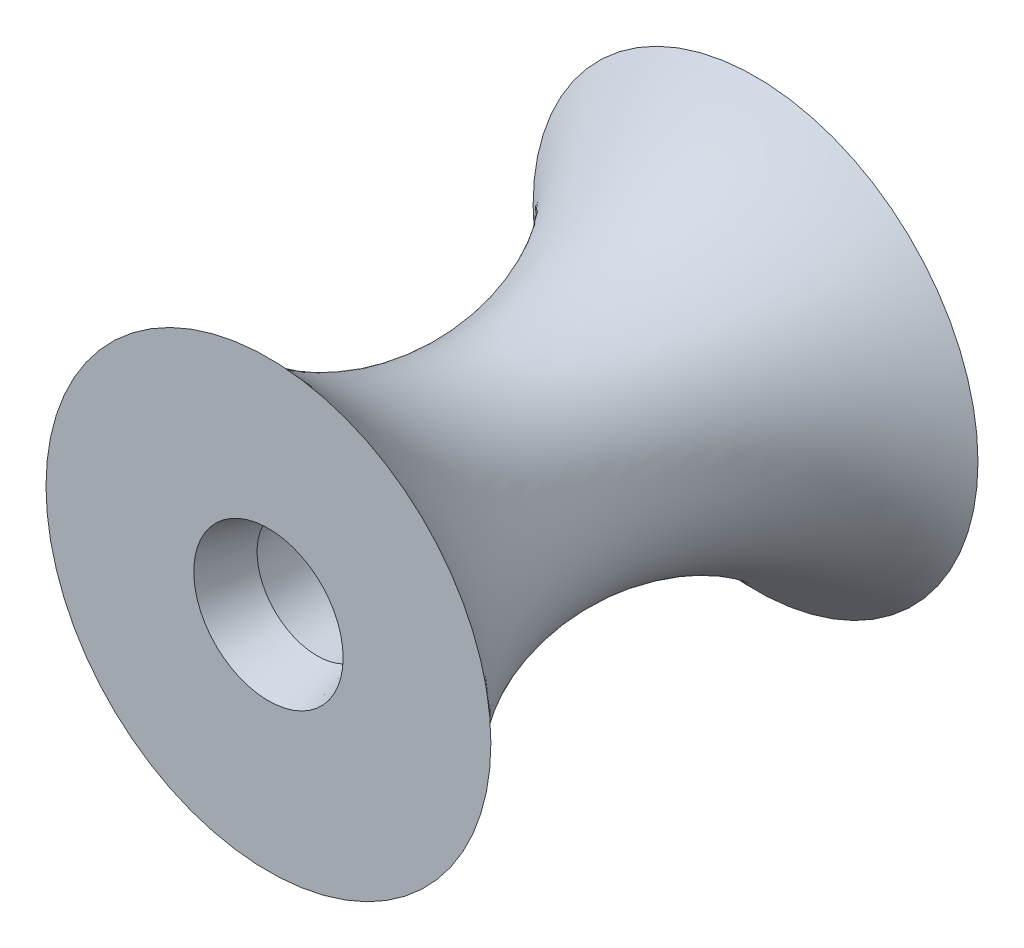
from build123d import *


with BuildPart() as part:
    # Sketch1 → Revolve1 (revolve)
    with BuildSketch(Plane(origin=(0, 0, 0), x_dir=(1, 0, 0), z_dir=(0, 1, 0))):
        with BuildLine():
            Line((-1.85, 13.5), (-1.85, 1.5))
            Line((-1.85, 1.5), (-2.3, 0))
            Line((-2.3, 0), (-6.85, 0))
            ThreePointArc((-6.85, 0), (-3.35, 7.5), (-6.85, 15))
            Line((-6.85, 15), (-2.3, 15))
            Line((-2.3, 15), (-1.85, 13.5))
        make_face()
    revolve(axis=Axis((0, 0, 0), (0, 0, -1)))


solid = part.part
